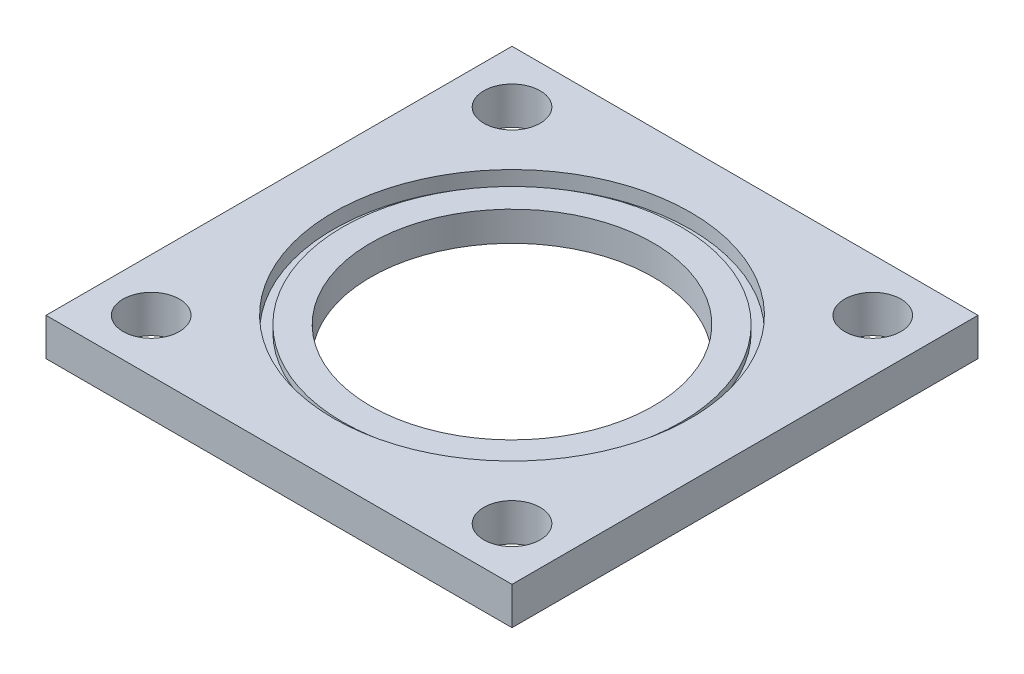
from build123d import *

# Parameters (mm, degrees)
PLATEOUTLINE_W      = 78.74
PLATEOUTLINE_H      = 78.74
BOSS_EXTRUDE1_DEPTH = 6.35
RAILGUIDES_R        = 4.7625
CUT_EXTRUDE1_DEPTH  = 10
CUT_EXTRUDE2_START  = 5
FUELGRAINMOUNTING_R = 30.1625
CUT_EXTRUDE2_DEPTH  = 5
GASINTAKE_R         = 23.876
CUT_EXTRUDE3_DEPTH  = 5
CUT_EXTRUDE4_START  = 3.857
SKETCH1_R           = 30.1625
SKETCH1_R_2         = 28.575
CUT_EXTRUDE4_DEPTH  = 1.143


with BuildPart() as part:
    # plateOutline → Boss-Extrude1 (new body)
    with BuildSketch(Plane(origin=(0, 0, 0), x_dir=(1, 0, 0), z_dir=(0, 1, 0))):
        Rectangle(PLATEOUTLINE_W, PLATEOUTLINE_H)
    extrude(amount=BOSS_EXTRUDE1_DEPTH)

    # railGuides → Cut-Extrude1 (cut)
    with BuildSketch(Plane(origin=(0, 0, 0), x_dir=(1, 0, 0), z_dir=(0, 1, 0))):
        with Locations((-30.48, 30.48)):
            Circle(RAILGUIDES_R)
        with Locations((30.48, 30.48)):
            Circle(RAILGUIDES_R)
        with Locations((30.48, -30.48)):
            Circle(RAILGUIDES_R)
        with Locations((-30.48, -30.48)):
            Circle(RAILGUIDES_R)
    extrude(amount=CUT_EXTRUDE1_DEPTH, mode=Mode.SUBTRACT)

    # FuelGrainMounting → Cut-Extrude2 (cut)
    with BuildSketch(Plane(origin=(0, 0, 0), x_dir=(1, 0, 0), z_dir=(0, 1, 0)).offset(CUT_EXTRUDE2_START)):
        Circle(FUELGRAINMOUNTING_R)
    extrude(amount=CUT_EXTRUDE2_DEPTH, mode=Mode.SUBTRACT)

    # GasIntake → Cut-Extrude3 (cut)
    with BuildSketch(Plane(origin=(0, 0, 0), x_dir=(1, 0, 0), z_dir=(0, 1, 0))):
        Circle(GASINTAKE_R)
    extrude(amount=CUT_EXTRUDE3_DEPTH, mode=Mode.SUBTRACT)

    # Sketch1 → Cut-Extrude4 (cut)
    with BuildSketch(Plane(origin=(0, 0, 0), x_dir=(1, 0, 0), z_dir=(0, 1, 0)).offset(CUT_EXTRUDE4_START)):
        Circle(SKETCH1_R)
        Circle(SKETCH1_R_2, mode=Mode.SUBTRACT)
    extrude(amount=CUT_EXTRUDE4_DEPTH, mode=Mode.SUBTRACT)


solid = part.part
